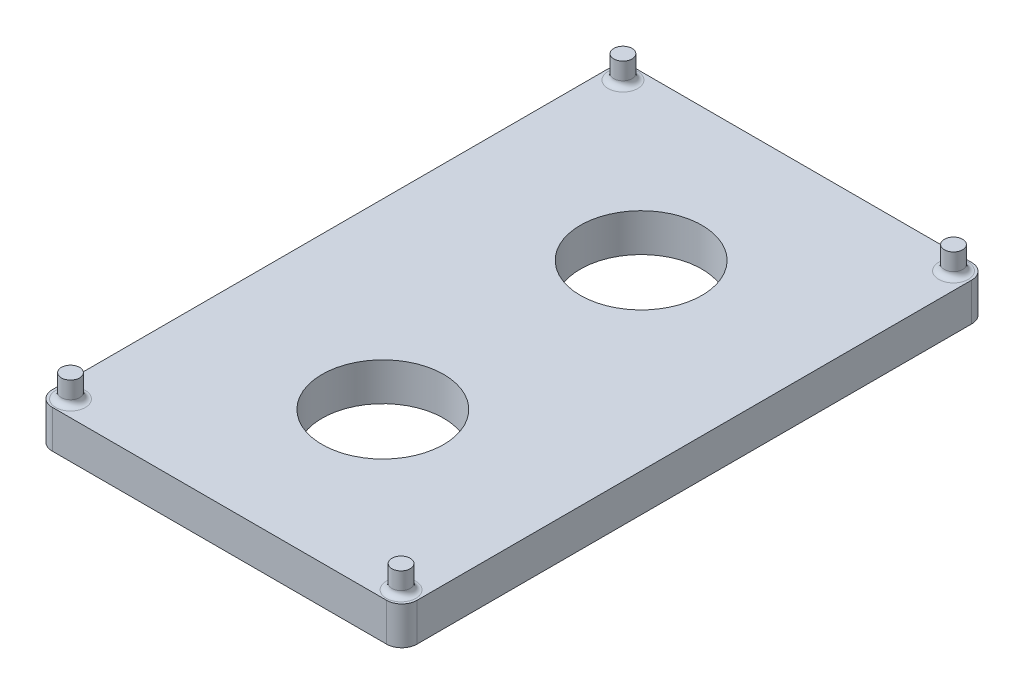
from build123d import *

# Parameters (mm, degrees)
SKETCH1_W           = 48
SKETCH1_H           = 77
BOSS_EXTRUDE1_DEPTH = 5
SKETCH2_R           = 1.2
BOSS_EXTRUDE2_DEPTH = 3
FILLET1_R           = 0.75
FILLET2_R           = 2
SKETCH3_R           = 8
CUT_EXTRUDE1_DEPTH  = 6


with BuildPart() as part:
    # Sketch1 → Boss-Extrude1 (new body)
    with BuildSketch(Plane(origin=(0, 0, 0), x_dir=(1, 0, 0), z_dir=(0, 1, 0))):
        with Locations((1.910432331, 3.349532818)):
            Rectangle(SKETCH1_W, SKETCH1_H)
    extrude(amount=BOSS_EXTRUDE1_DEPTH)

    # Sketch2 → Boss-Extrude2 (add)
    with BuildSketch(Plane(origin=(0, 5, 0), x_dir=(1, 0, 0), z_dir=(0, 1, 0))):
        with Locations((-19.839567669, 39.699532818)):
            Circle(SKETCH2_R)
        with Locations((23.660432331, 39.699532818)):
            Circle(SKETCH2_R)
        with Locations((23.660432331, -33.000467182)):
            Circle(SKETCH2_R)
        with Locations((-19.839567669, -33.000467182)):
            Circle(SKETCH2_R)
    extrude(amount=BOSS_EXTRUDE2_DEPTH)

    # Fillet1
    fillet1_edges = [part.edges().sort_by_distance(p)[0] for p in [
        (-21.039567669, 5, -39.699532818),
        (22.460432331, 5, -39.699532818),
        (22.460432331, 5, 33.000467182),
        (-21.039567669, 5, 33.000467182),
    ]]
    fillet(fillet1_edges, radius=FILLET1_R)

    # Fillet2
    fillet2_edges = [part.edges().sort_by_distance(p)[0] for p in [
        (-22.089567669, 2.5, -41.849532818),
        (25.910432331, 2.5, -41.849532818),
        (25.910432331, 2.5, 35.150467182),
        (-22.089567669, 2.5, 35.150467182),
    ]]
    fillet(fillet2_edges, radius=FILLET2_R)

    # Sketch3 → Cut-Extrude1 (cut, through all)
    with BuildSketch(Plane(origin=(0, 5, 0), x_dir=(1, 0, 0), z_dir=(0, 1, 0))):
        with Locations((1.910432331, 20.344226446)):
            Circle(SKETCH3_R)
        with Locations((1.910432331, -13.645160811)):
            Circle(SKETCH3_R)
    extrude(amount=-CUT_EXTRUDE1_DEPTH, mode=Mode.SUBTRACT)


solid = part.part
